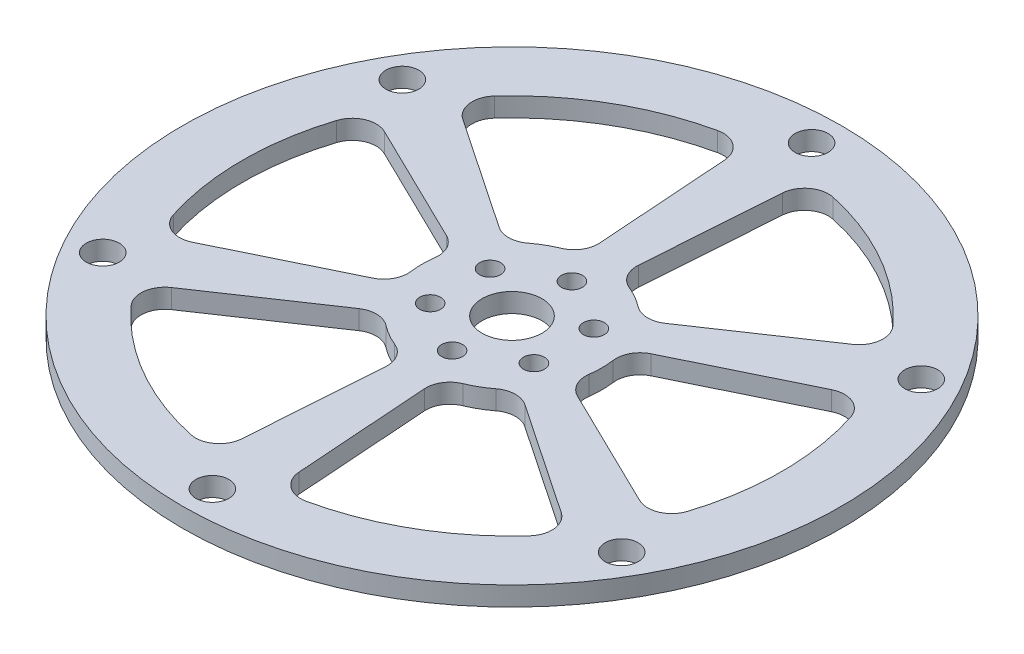
from build123d import *

# Parameters (mm, degrees)
SKETCH1_R                = 15
SKETCH1_R_2              = 5
BOSS_EXTRUDE1_DEPTH      = 3.2
SKETCH2_R                = 55
SKETCH2_R_2              = 45
BOSS_EXTRUDE2_DEPTH      = 3.2
BOSS_EXTRUDE3_DEPTH      = 3.2
SKETCH3_R                = 1.75
CUT_EXTRUDE2_DEPTH       = 4.2
SKETCH4_R                = 2.75
CUT_EXTRUDE3_DEPTH       = 4.2
FILLET1_R                = 4
CIRPATTERN1_COUNT        = 6
FILLET1_OF_CIRPATTERN1_R = 4
CIRPATTERN2_COUNT        = 6


with BuildPart() as part:
    # Sketch1 → Boss-Extrude1 (new body)
    with BuildSketch(Plane(origin=(0, 0, 0), x_dir=(1, 0, 0), z_dir=(0, 1, 0))):
        Circle(SKETCH1_R)
        Circle(SKETCH1_R_2, mode=Mode.SUBTRACT)
    extrude(amount=BOSS_EXTRUDE1_DEPTH)



with BuildPart() as body_2:
    # Sketch2 → Boss-Extrude2 (new body)
    with BuildSketch(Plane(origin=(0, 0, 0), x_dir=(1, 0, 0), z_dir=(0, 1, 0))):
        Circle(SKETCH2_R)
        Circle(SKETCH2_R_2, mode=Mode.SUBTRACT)
    extrude(amount=BOSS_EXTRUDE2_DEPTH)


with BuildPart() as part_1:
    add(part.part)

    add(body_2.part)  # Boss-Extrude3 merges body 2
    # Sketch5 → Boss-Extrude3 (add)
    with BuildSketch(Plane(origin=(0, 0, 0), x_dir=(1, 0, 0), z_dir=(0, 1, 0))):
        with BuildLine():
            Line((-5.098732434, 44.710210552), (-3, 14.696938457))
            ThreePointArc((-3, 14.696938457), (0, 15), (3, 14.696938457))
            Line((3, 14.696938457), (5.098732434, 44.710210552))
            ThreePointArc((5.098732434, 44.710210552), (0, 45), (-5.098732434, 44.710210552))
        make_face()
    boss_extrude3 = extrude(amount=BOSS_EXTRUDE3_DEPTH)

    # Sketch3 → Cut-Extrude2 (cut, through all)
    with BuildSketch(Plane(origin=(0, 0, 0), x_dir=(1, 0, 0), z_dir=(0, 1, 0))):
        with Locations((0, 10)):
            Circle(SKETCH3_R)
    cut_extrude2 = extrude(amount=CUT_EXTRUDE2_DEPTH, mode=Mode.SUBTRACT)

    # Sketch4 → Cut-Extrude3 (cut, through all)
    with BuildSketch(Plane(origin=(0, 0, 0), x_dir=(1, 0, 0), z_dir=(0, 1, 0))):
        with Locations((0, 50)):
            Circle(SKETCH4_R)
    cut_extrude3 = extrude(amount=CUT_EXTRUDE3_DEPTH, mode=Mode.SUBTRACT)

    # Fillet1
    fillet1_edges = [part_1.edges().sort_by_distance(p)[0] for p in [
        (5.098732434, 1.6, -44.710210552),
        (-5.098732434, 1.6, -44.710210552),
        (-3, 1.6, -14.696938457),
        (3, 1.6, -14.696938457),
    ]]
    fillet(fillet1_edges, radius=FILLET1_R)

    # CirPattern1: Boss-Extrude3, Cut-Extrude3 ×6 about axis
    cirpattern1_axis = Axis((0, 0, 0), (0, 1, 0))
    for i in range(1, CIRPATTERN1_COUNT):
        add(boss_extrude3.rotate(cirpattern1_axis, i * 360 / CIRPATTERN1_COUNT))
        add(cut_extrude3.rotate(cirpattern1_axis, i * 360 / CIRPATTERN1_COUNT), mode=Mode.SUBTRACT)

    # Fillet1 of CirPattern1
    fillet1_of_cirpattern1_edges = [part_1.edges().sort_by_distance(p)[0] for p in [
        (-36.170811929, 1.6, -26.77073709),
        (-41.269544363, 1.6, -17.939473461),
        (-14.227922061, 1.6, -4.750393017),
        (-11.227922061, 1.6, -9.94654544),
        (-41.269544363, 1.6, 17.939473461),
        (-36.170811929, 1.6, 26.77073709),
        (-11.227922061, 1.6, 9.94654544),
        (-14.227922061, 1.6, 4.750393017),
        (-5.098732434, 1.6, 44.710210552),
        (5.098732434, 1.6, 44.710210552),
        (3, 1.6, 14.696938457),
        (-3, 1.6, 14.696938457),
        (36.170811929, 1.6, 26.77073709),
        (41.269544363, 1.6, 17.939473461),
        (14.227922061, 1.6, 4.750393017),
        (11.227922061, 1.6, 9.94654544),
        (41.269544363, 1.6, -17.939473461),
        (36.170811929, 1.6, -26.77073709),
        (11.227922061, 1.6, -9.94654544),
        (14.227922061, 1.6, -4.750393017),
    ]]
    fillet(fillet1_of_cirpattern1_edges, radius=FILLET1_OF_CIRPATTERN1_R)

    # CirPattern2: Cut-Extrude2 ×6 about axis
    cirpattern2_axis = Axis((0, 0, 0), (0, 1, 0))
    for i in range(1, CIRPATTERN2_COUNT):
        add(cut_extrude2.rotate(cirpattern2_axis, i * 360 / CIRPATTERN2_COUNT), mode=Mode.SUBTRACT)


solid = part_1.part
